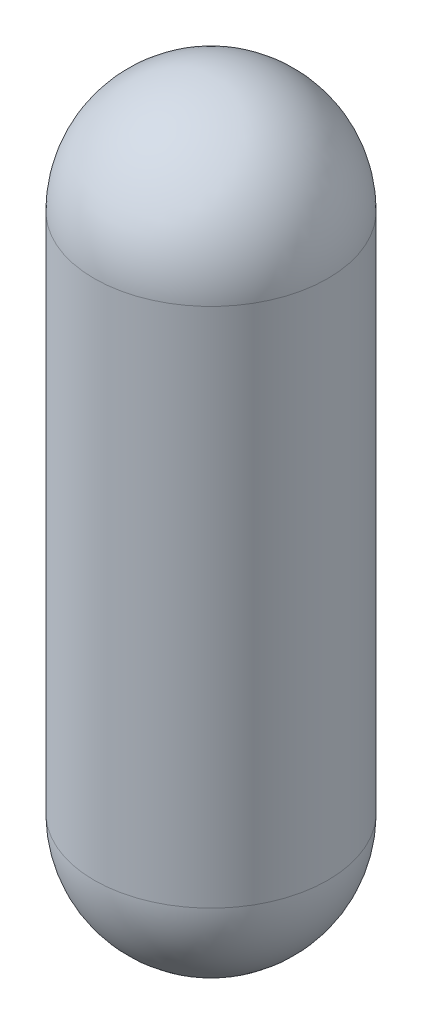
from build123d import *


with BuildPart() as part:
    # Sketch1 → Revolve1 (revolve)
    with BuildSketch(Plane.XY):
        with BuildLine():
            Line((-82.55, -82.55), (-82.55, -450.85))
            ThreePointArc((-82.55, -450.85), (-58.371664787, -509.221664787), (0, -533.4))
            Line((0, -533.4), (0, 0))
            ThreePointArc((0, 0), (-58.371664787, -24.178335213), (-82.55, -82.55))
        make_face()
    revolve(axis=Axis((0, -533.4, 0), (0, 1, 0)))


solid = part.part
